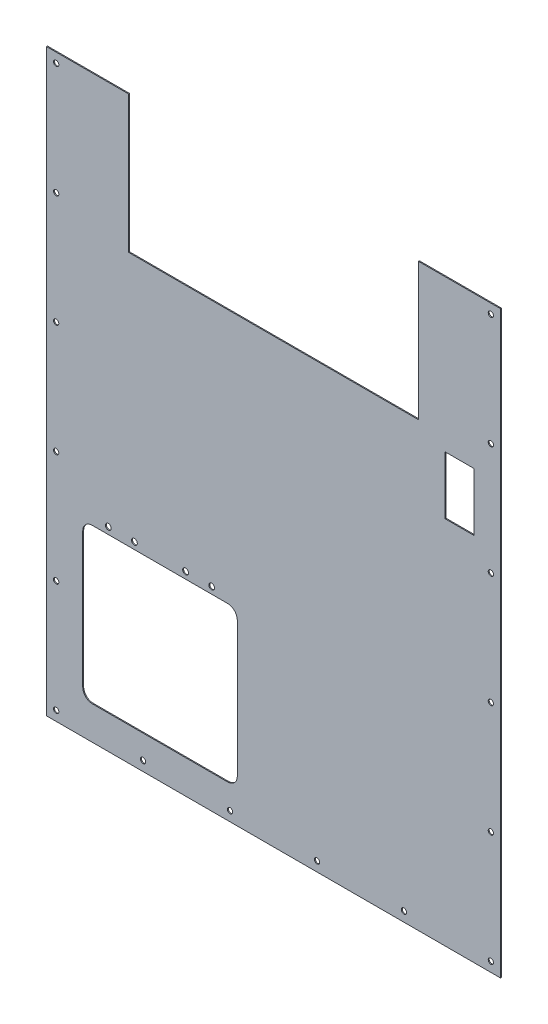
from build123d import *

# Parameters (mm, degrees)
SKETCH_1_W          = 470
SKETCH_1_H          = 600
EXTRUDE_1_DEPTH     = 1
HOLE_WIZARD_M5_1_D  = 5.5
SKETCH_1_3_W        = 300
SKETCH_1_3_H        = 142
CUT_EXTRUDE_3_DEPTH = 10
SKETCH_4_W          = 30
SKETCH_4_H          = 60
CUT_EXTRUDE_4_DEPTH = 10
SKETCH_5_R          = 3
CUT_EXTRUDE_5_DEPTH = 10


with BuildPart() as part:
    # 스케치1 → 보스-돌출1 (new body)
    with BuildSketch(Plane.XY):
        Rectangle(SKETCH_1_W, SKETCH_1_H)
    extrude(amount=EXTRUDE_1_DEPTH)

    # M5 여유 구멍1 (through all)
    with Locations(Plane(origin=(0, 0, 0), x_dir=(-1, 0, 0), z_dir=(0, 0, -1))):
        with Locations((-225, 290), (-135, 290), (-45, 290), (45, 290), (135, 290), (225, 290), (225, 174), (225, 58), (225, -58), (225, -174), (225, -290), (-225, 174), (-225, 58), (-225, -58), (-225, -174), (-225, -290), (-135, -290), (-45, -290), (45, -290), (135, -290)):
            Hole(HOLE_WIZARD_M5_1_D / 2)

    # 스케치1<3> → 컷-돌출3 (cut)
    with BuildSketch(Plane.XY):
        with Locations((0, 229)):
            Rectangle(SKETCH_1_3_W, SKETCH_1_3_H)
    extrude(amount=CUT_EXTRUDE_3_DEPTH, mode=Mode.SUBTRACT)

    # 스케치4 → 컷-돌출4 (cut)
    with BuildSketch(Plane.XY.offset(1)):
        with Locations((192.5, 113)):
            Rectangle(SKETCH_4_W, SKETCH_4_H)
        with BuildLine():
            Line((-187.5, -105.5), (-47.5, -105.5))
            ThreePointArc((-47.5, -105.5), (-40.428932188, -108.428932188), (-37.5, -115.5))
            Line((-37.5, -115.5), (-37.5, -255.5))
            ThreePointArc((-37.5, -255.5), (-40.428932188, -262.571067812), (-47.5, -265.5))
            Line((-47.5, -265.5), (-187.5, -265.5))
            ThreePointArc((-187.5, -265.5), (-194.571067812, -262.571067812), (-197.5, -255.5))
            Line((-197.5, -255.5), (-197.5, -115.5))
            ThreePointArc((-197.5, -115.5), (-194.571067812, -108.428932188), (-187.5, -105.5))
        make_face()
    extrude(amount=-CUT_EXTRUDE_4_DEPTH, mode=Mode.SUBTRACT)

    # 스케치5 → 컷-돌출5 (cut)
    with BuildSketch(Plane.XY.offset(1)):
        with Locations((-171, -98.5)):
            Circle(SKETCH_5_R)
        with Locations((-144, -98.5)):
            Circle(SKETCH_5_R)
        with Locations((-91, -98.5)):
            Circle(SKETCH_5_R)
        with Locations((-64, -98.5)):
            Circle(SKETCH_5_R)
    extrude(amount=-CUT_EXTRUDE_5_DEPTH, mode=Mode.SUBTRACT)


solid = part.part
